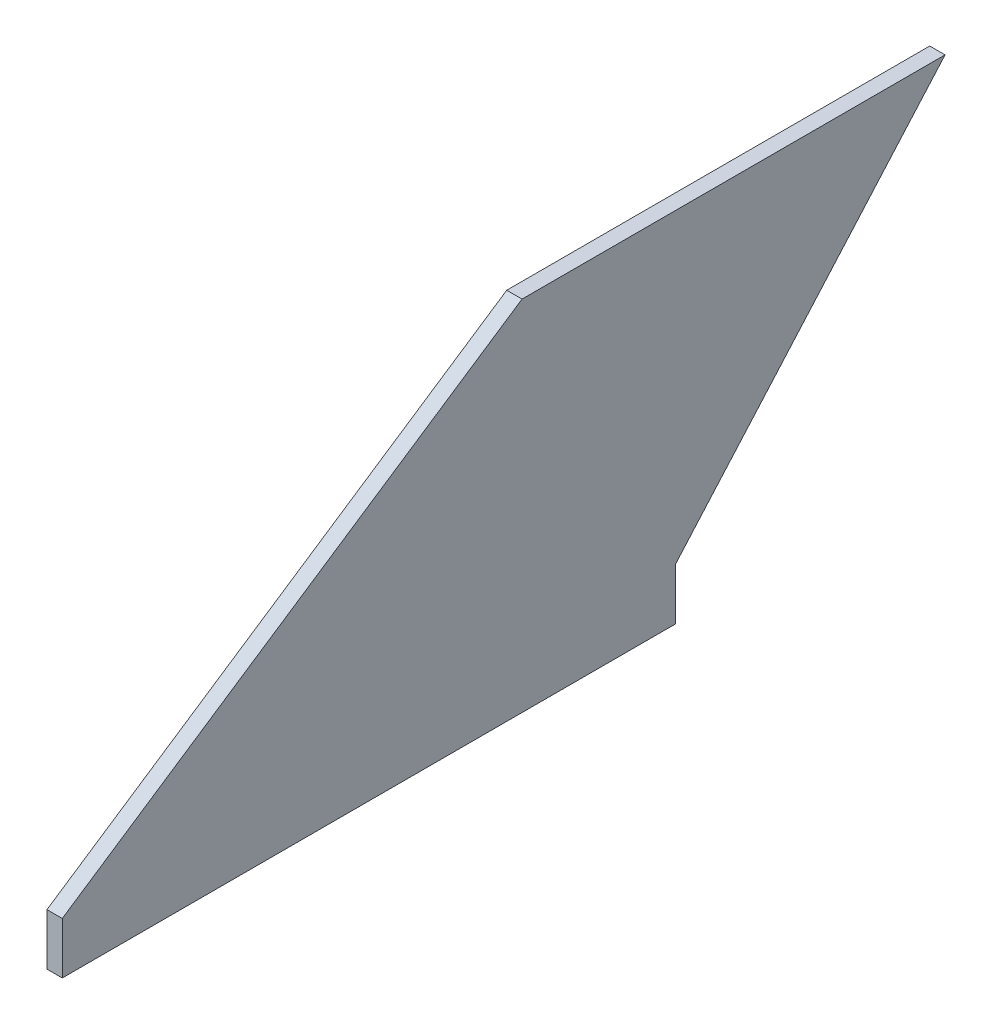
from build123d import *

# Parameters (mm, degrees)
BOSS_EXTRUDE1_DEPTH = 3.175


with BuildPart() as part:
    # Sketch2 → Boss-Extrude1 (new body)
    with BuildSketch(Plane(origin=(0, 0, 0), x_dir=(0, 0, -1), z_dir=(1, 0, 0))):
        Polygon((0, 0), (95.25, 63.5), (182.88, 63.5), (127, 0), (127, -10.6807), (0, -10.6807), align=None)
    extrude(amount=BOSS_EXTRUDE1_DEPTH)


solid = part.part
